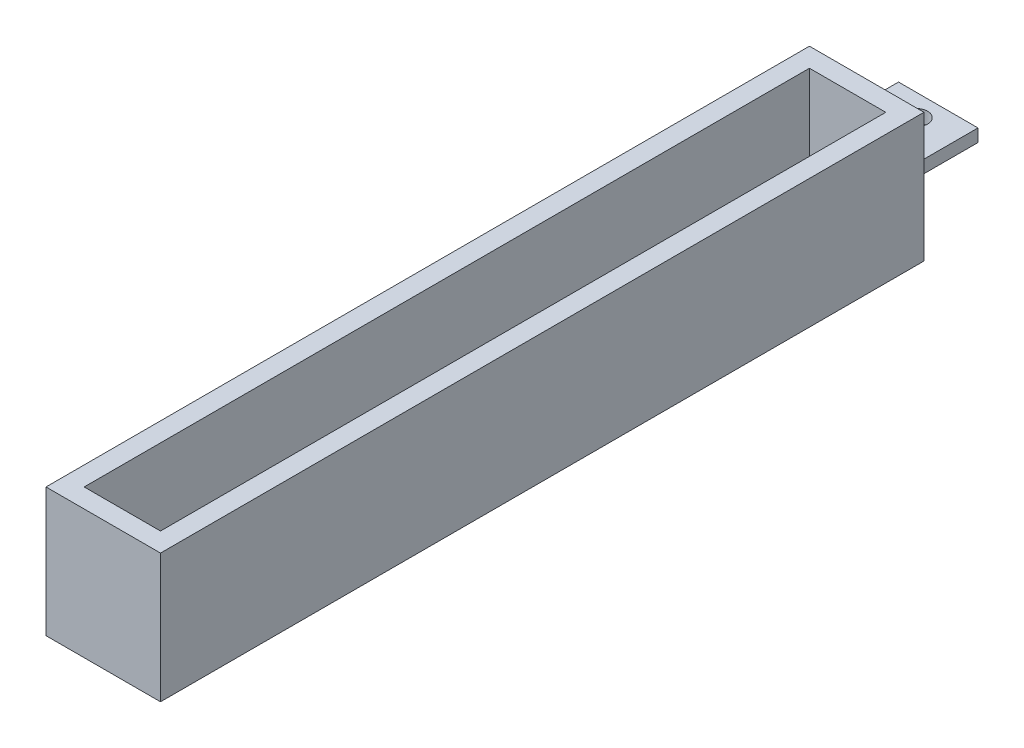
from build123d import *

# Parameters (mm, degrees)
SKETCH1_W           = 24
SKETCH1_H           = 27
BOSS_EXTRUDE1_DEPTH = 160
SHELL1_T            = -4
SKETCH2_W           = 16.655936622
SKETCH2_H           = 2.65564638
BOSS_EXTRUDE2_DEPTH = 15
SKETCH3_R           = 2.351991257
CUT_EXTRUDE1_DEPTH  = 15.82782319


with BuildPart() as part:
    # Sketch1 → Boss-Extrude1 (new body)
    with BuildSketch(Plane.XY):
        with Locations((12, 13.5)):
            Rectangle(SKETCH1_W, SKETCH1_H)
    extrude(amount=BOSS_EXTRUDE1_DEPTH)

    # Shell1
    shell1_openings = [part.faces().sort_by_distance(p)[0] for p in [
        (12, 27, 80),
    ]]
    offset(amount=SHELL1_T, openings=shell1_openings, kind=Kind.INTERSECTION)

    # Sketch2 → Boss-Extrude2 (add)
    with BuildSketch(Plane(origin=(0, 0, 0), x_dir=(-1, 0, 0), z_dir=(0, 0, -1))):
        with Locations((-12, 13.5)):
            Rectangle(SKETCH2_W, SKETCH2_H)
    extrude(amount=BOSS_EXTRUDE2_DEPTH)

    # Sketch3 → Cut-Extrude1 (cut, through all)
    with BuildSketch(Plane(origin=(0, 14.82782319, 0), x_dir=(1, 0, 0), z_dir=(0, 1, 0))):
        with Locations((12, 10.403093439)):
            Circle(SKETCH3_R)
    extrude(amount=-CUT_EXTRUDE1_DEPTH, mode=Mode.SUBTRACT)


solid = part.part
